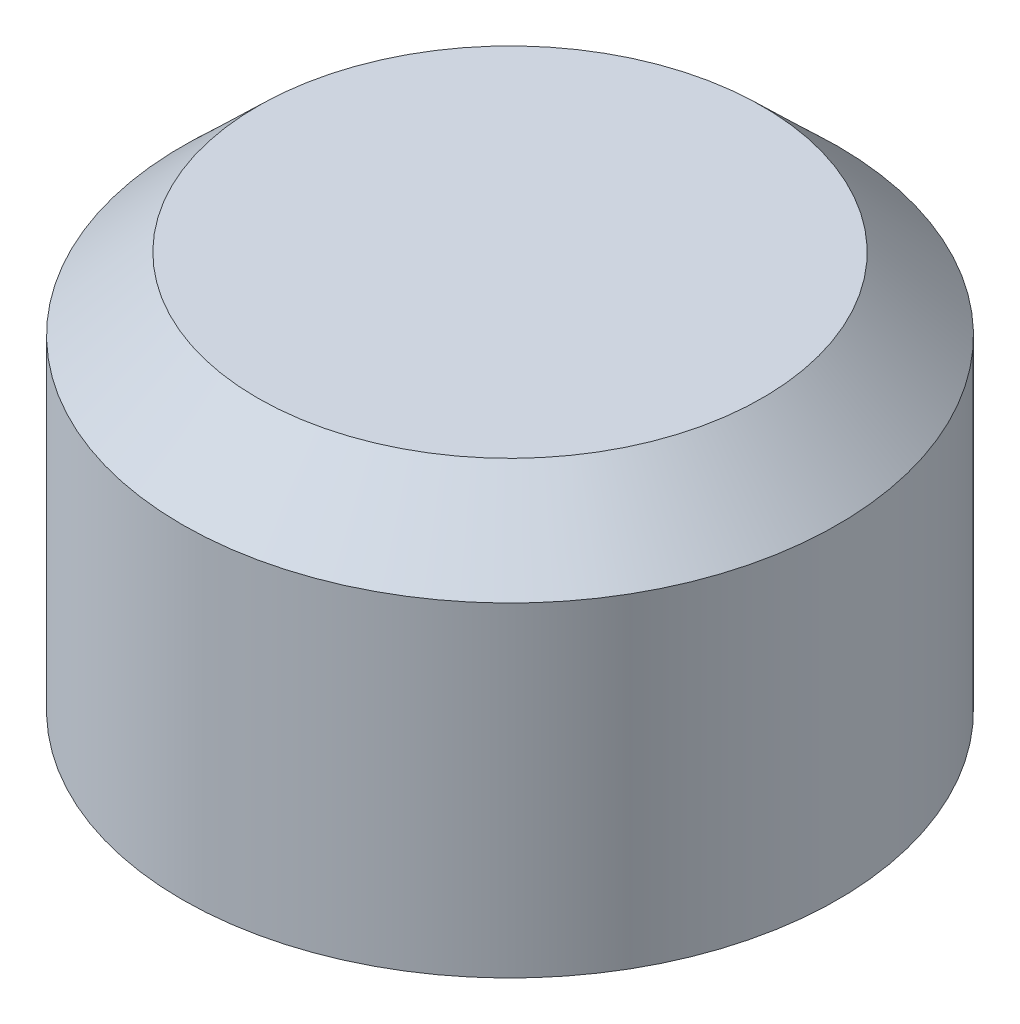
from build123d import *


with BuildPart() as part:
    # Sketch1 → Revolve1 (revolve)
    with BuildSketch(Plane.XY):
        Polygon((-2438.4, 0), (-2438.4, 2753.721024484), (-2118.721024484, 3073.4), (-1190.8772065, 3073.4), (-914.4, 2796.9227935), (-914.4, 1524), (-939.8, 1524), (-939.8, 2786.401769016), (-1201.398230984, 3048), (-2108.2, 3048), (-2413, 2743.2), (-2413, 0), align=None)
    revolve(axis=Axis((0, 3520.44, 0), (0, -1, 0)))


with BuildPart() as body_2:
    # Sketch2 → Revolve2 (revolve)
    with BuildSketch(Plane.XY):
        Polygon((-2743.2, 0), (-2768.6, 0), (-2768.6, 2743.2), (-2133.6, 3352.8), (0, 3352.8), (0, 3327.4), (-2123.381318695, 3327.4), (-2743.2, 2732.374065947), align=None)
    revolve(axis=Axis((0, 3520.44, 0), (0, -1, 0)))


solid = Compound([part.part, body_2.part])
